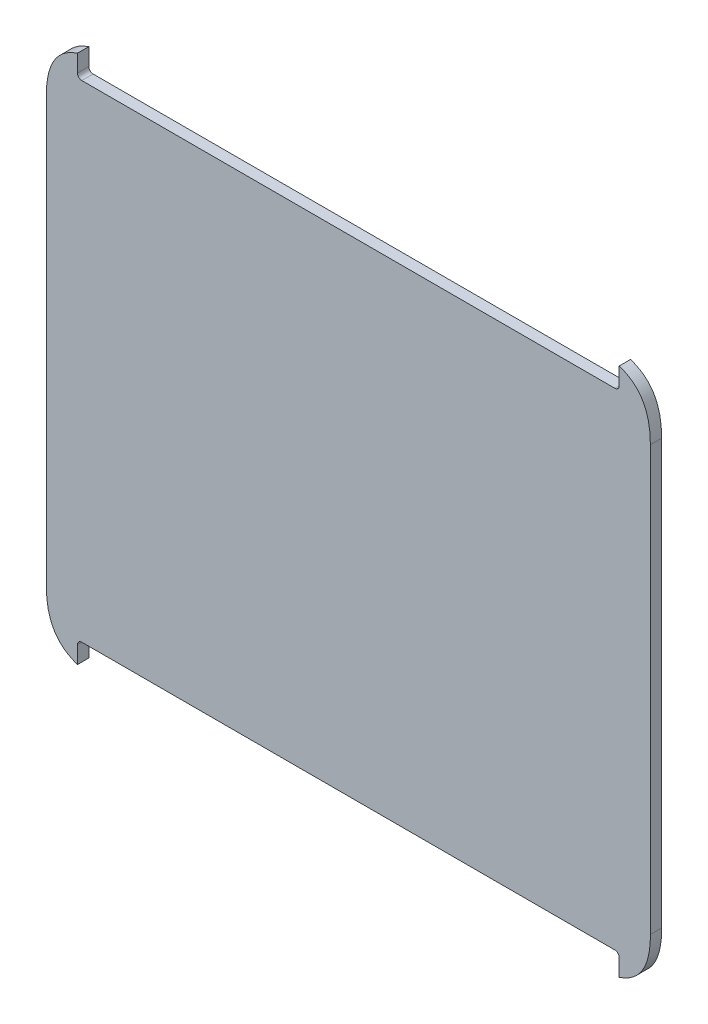
from build123d import *

# Parameters (mm, degrees)
BOSS_EXTRUDE1_DEPTH = 12.7


with BuildPart() as part:
    # Sketch1 → Boss-Extrude1 (new body)
    with BuildSketch(Plane.XY):
        with BuildLine():
            Line((-20.574, -61.084457743), (578.569437198, -61.084457743))
            ThreePointArc((578.569437198, -61.084457743), (581.981934524, -59.670955069), (583.395437198, -56.258457743))
            Line((583.395437198, -56.258457743), (583.395437198, -36.911371471))
            add(Edge.make_bspline(
                [(583.395437198, -36.911371471), (610.890329995, -46.033932746), (618.425396158, -69.67439137), (618.425396158, -96.114416703)],
                knots=[0, 0, 0, 0, 1, 1, 1, 1], degree=3))
            Line((618.425396158, -96.114416703), (618.425396158, -572.727698858))
            add(Edge.make_bspline(
                [(583.395437198, -631.93074409), (610.890329995, -622.808182814), (618.425396158, -599.167724191), (618.425396158, -572.727698858)],
                knots=[0, 0, 0, 0, 1, 1, 1, 1], degree=3))
            Line((583.395437198, -631.93074409), (583.395437198, -612.583657817))
            ThreePointArc((583.395437198, -612.583657817), (581.981934524, -609.171160491), (578.569437198, -607.757657817))
            Line((578.569437198, -607.757657817), (-20.574, -607.757657817))
            ThreePointArc((-20.574, -607.757657817), (-23.986497326, -609.171160491), (-25.4, -612.583657817))
            Line((-25.4, -612.583657817), (-25.4, -631.93074409))
            add(Edge.make_bspline(
                [(-25.4, -631.93074409), (-52.894892797, -622.808182814), (-60.42995896, -599.167724191), (-60.42995896, -572.727698858)],
                knots=[0, 0, 0, 0, 1, 1, 1, 1], degree=3))
            Line((-60.42995896, -572.727698858), (-60.42995896, -96.114416703))
            add(Edge.make_bspline(
                [(-25.4, -36.911371471), (-52.894892797, -46.033932746), (-60.42995896, -69.67439137), (-60.42995896, -96.114416703)],
                knots=[0, 0, 0, 0, 1, 1, 1, 1], degree=3))
            Line((-25.4, -36.911371471), (-25.4, -56.258457743))
            ThreePointArc((-25.4, -56.258457743), (-23.986497326, -59.670955069), (-20.574, -61.084457743))
        make_face()
    extrude(amount=BOSS_EXTRUDE1_DEPTH)


solid = part.part
